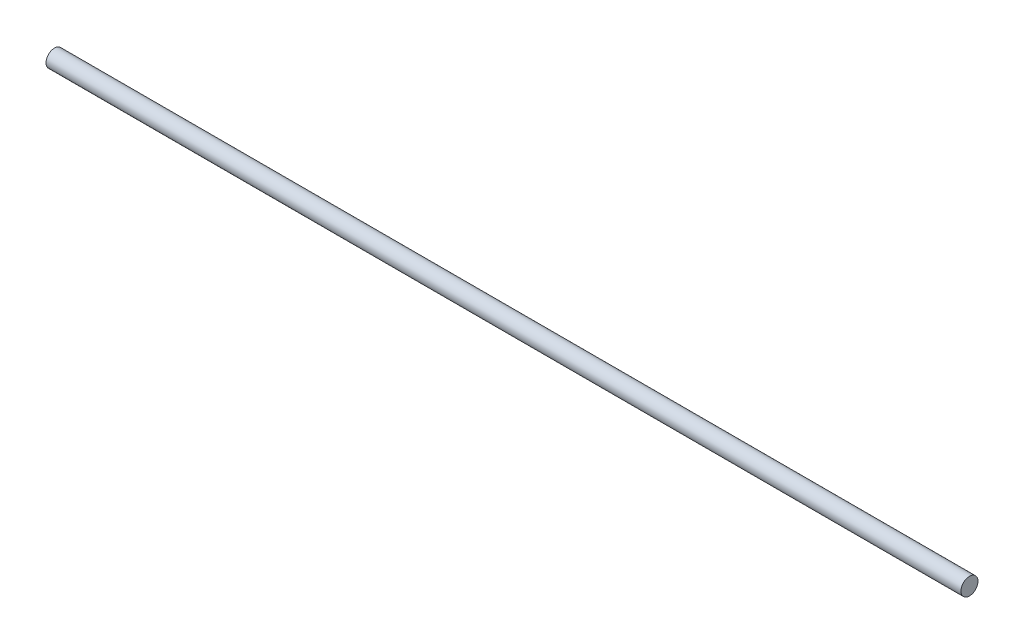
from build123d import *

# Parameters (mm, degrees)
SKETCH1_R           = 3
SKETCH1_R_2         = 0.003
BOSS_EXTRUDE1_DEPTH = 161


with BuildPart() as part:
    # Sketch1 → Boss-Extrude1 (new body, symmetric)
    with BuildSketch(Plane(origin=(0, 0, 0), x_dir=(0, 0, -1), z_dir=(1, 0, 0))):
        Circle(SKETCH1_R)
        Circle(SKETCH1_R_2, mode=Mode.SUBTRACT)
    extrude(amount=BOSS_EXTRUDE1_DEPTH, both=True)


solid = part.part
